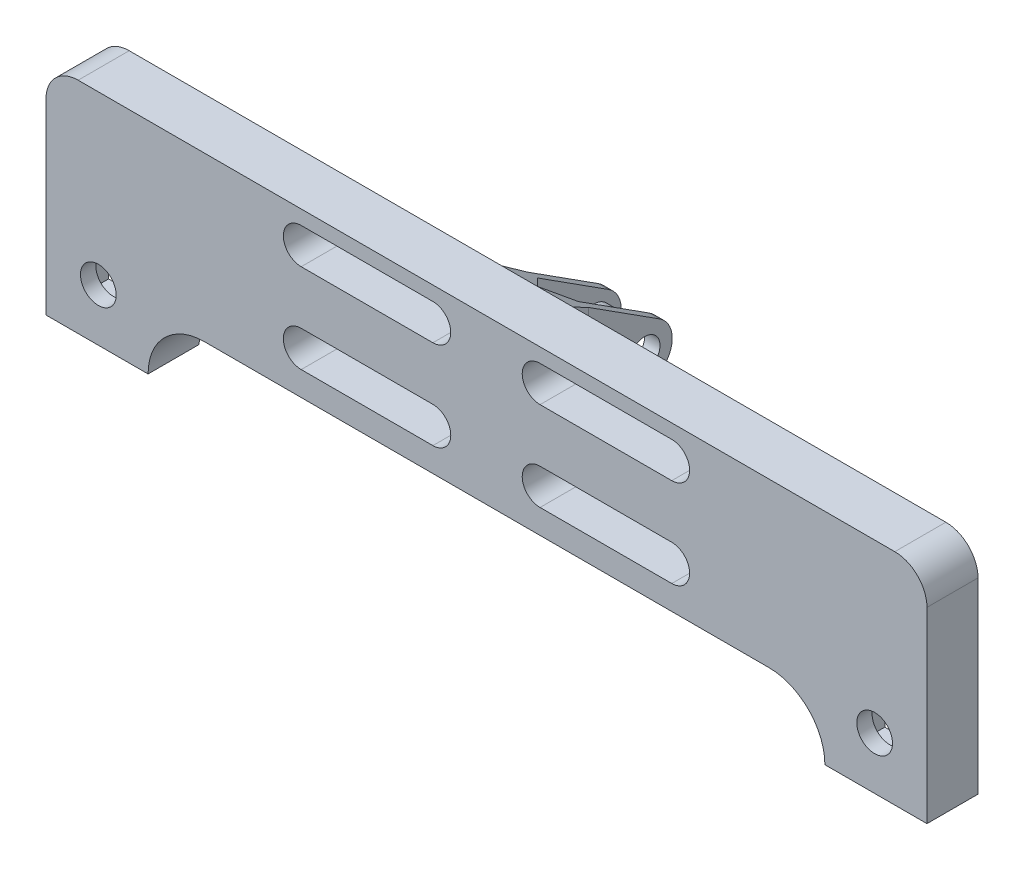
from build123d import *

# Parameters (mm, degrees)
SKETCH1_R               = 4.3000000000000025
BOSS_EXTRUDE1_DEPTH     = 8
CUT_EXTRUDE1_DEPTH      = 8
SKETCH1_2_R             = 4.3000000000000025
BOSS_EXTRUDE2_DEPTH     = 10
CUT_EXTRUDE2_DEPTH      = 92.31190849955428
CUT_EXTRUDE2_DEPTH_BACK = 92.31190849955428
SKETCH3_W               = 12.499999999999986
SKETCH3_H               = 12.500000000000002
SKETCH3_W_2             = 12.5
SKETCH3_H_2             = 12.5
BOSS_EXTRUDE3_DEPTH     = 2
BOSS_EXTRUDE5_START     = -2
SKETCH4_R               = 4.3000000000000025
BOSS_EXTRUDE5_DEPTH     = 2
BOSS_EXTRUDE6_DEPTH     = 10.000000000000002
BOSS_EXTRUDE7_DEPTH     = 10.000000000000002
BOSS_EXTRUDE8_DEPTH     = 10
SKETCH8_W               = 18.12209127979392
SKETCH8_H               = 22.505010210713824
SKETCH8_W_2             = 16.915072938743947
SKETCH8_H_2             = 18.768490123640905
BOSS_EXTRUDE9_DEPTH     = 10
SKETCH12_W              = 16.5
SKETCH12_H              = 16.500000000000004
CUT_EXTRUDE6_DEPTH      = 6.999999999999999
SKETCH13_R              = 3.5000000000000075
CUT_EXTRUDE7_DEPTH      = 6.999999999999999
CUT_EXTRUDE11_DEPTH     = 5
BOSS_EXTRUDE10_DEPTH    = 8
BOSS_EXTRUDE11_START    = -10.000000000000002
BOSS_EXTRUDE11_DEPTH    = 10.000000000000002
BOSS_EXTRUDE12_START    = -10.000000000000002
BOSS_EXTRUDE12_DEPTH    = 10.000000000000002
BOSS_EXTRUDE13_DEPTH    = 20
CUT_EXTRUDE12_DEPTH     = 20
SKETCH20_R              = 3.5
CUT_EXTRUDE13_DEPTH     = 20
SKETCH21_W              = 12.588800468492423
SKETCH21_H              = 27.872981801920105
CUT_EXTRUDE15_DEPTH     = 28.00000000000001
SKETCH23_W              = 2.0000000000000004
SKETCH23_H              = 31.999999999999986
BOSS_EXTRUDE14_DEPTH    = 25
SKETCH24_R              = 2.9999999999999996
CUT_EXTRUDE16_DEPTH     = 25
CUT_EXTRUDE18_DEPTH     = 25
BOSS_EXTRUDE15_REACH    = 105.846
CUT_EXTRUDE19_REACH     = 101.389
CUT_EXTRUDE20_REACH     = 101.389
SKETCH31_W              = 16.5
SKETCH31_H              = 16.500000000000004
BOSS_EXTRUDE16_DEPTH    = 7
SKETCH32_R              = 4.3000000000000025
SKETCH32_R_2            = 4.0500000000000025
BOSS_EXTRUDE17_DEPTH    = 10
BOSS_EXTRUDE18_START    = 2
SKETCH33_R              = 3.5000000000000018
SKETCH33_R_2            = 2.9999999999999996
BOSS_EXTRUDE18_DEPTH    = 2
SKETCH34_R              = 3.4999999999999996
SKETCH34_R_2            = 3.0000000000000013
BOSS_EXTRUDE19_DEPTH    = 1


with BuildPart() as part:
    # Sketch1 → Boss-Extrude1 (new body)
    with BuildSketch(Plane.XY):
        with BuildLine():
            Line((-85.34534606205251, -25.7), (87.25465393794748, -25.7))
            Line((87.25465393794748, -25.7), (87.25465393794748, 0))
            ThreePointArc((87.25465393794748, 0), (85.40942665942275, 4.454772721475249), (80.9546539379475, 6.3))
            Line((80.9546539379475, 6.3), (-79.04534606205252, 6.3))
            ThreePointArc((-79.04534606205252, 6.3), (-83.50011878352777, 4.4547727214752495), (-85.34534606205251, -7.7e-16))
            Line((-85.34534606205251, -7.7e-16), (-85.34534606205251, -25.7))
        make_face()
        with Locations((-79.04534606205252, 0)):
            Circle(SKETCH1_R, mode=Mode.SUBTRACT)
        with Locations((80.9546539379475, 0)):
            Circle(SKETCH1_R, mode=Mode.SUBTRACT)
        Polygon((-83.3453460620525, -11.200000000000001), (-70.8453460620525, -11.199999999999998), (-70.84534606205251, -23.7), (-83.34534606205251, -23.7), align=None, mode=Mode.SUBTRACT)
        Polygon((85.2546539379475, -11.199999999999966), (72.7546539379475, -11.199999999999967), (72.7546539379475, -23.69999999999997), (85.2546539379475, -23.699999999999967), align=None, mode=Mode.SUBTRACT)
    extrude(amount=BOSS_EXTRUDE1_DEPTH)

    # Sketch2 → Cut-Extrude1 (cut)
    with BuildSketch(Plane.XY.offset(8)):
        with BuildLine():
            Line((-35.34534606205251, 3.4999999999999996), (37.25465393794748, 3.4999999999999996))
            ThreePointArc((37.25465393794748, 3.4999999999999996), (40.75465393794748, 0), (37.25465393794748, -3.4999999999999996))
            Line((37.25465393794748, -3.4999999999999996), (-35.34534606205251, -3.4999999999999996))
            ThreePointArc((-35.34534606205251, -3.4999999999999996), (-38.84534606205251, 4.3e-16), (-35.34534606205251, 3.4999999999999996))
        make_face()
        with BuildLine():
            Line((-35.34534606205251, -13.949999999999969), (37.25465393794749, -13.949999999999969))
            ThreePointArc((37.25465393794749, -13.949999999999969), (40.75465393794748, -17.449999999999967), (37.25465393794749, -20.949999999999967))
            Line((37.25465393794749, -20.949999999999967), (34.64320743131566, -20.949999999999967))
            Line((34.64320743131566, -20.949999999999967), (-35.34534606205251, -20.949999999999967))
            ThreePointArc((-35.34534606205251, -20.949999999999967), (-38.845346062052506, -17.449999999999967), (-35.34534606205251, -13.949999999999969))
        make_face()
    extrude(amount=-CUT_EXTRUDE1_DEPTH, mode=Mode.SUBTRACT)

    # Sketch1_2 → Boss-Extrude2 (add)
    with BuildSketch(Plane.XY):
        with BuildLine():
            Line((-85.34534606205251, -25.7), (87.25465393794748, -25.7))
            Line((87.25465393794748, -25.7), (87.25465393794748, 0))
            ThreePointArc((87.25465393794748, 0), (85.40942665942275, 4.454772721475249), (80.9546539379475, 6.3))
            Line((80.9546539379475, 6.3), (-79.04534606205252, 6.3))
            ThreePointArc((-79.04534606205252, 6.3), (-83.50011878352777, 4.4547727214752495), (-85.34534606205251, -7.7e-16))
            Line((-85.34534606205251, -7.7e-16), (-85.34534606205251, -25.7))
        make_face()
        with Locations((-79.04534606205252, 0)):
            Circle(SKETCH1_2_R, mode=Mode.SUBTRACT)
        with Locations((80.9546539379475, 0)):
            Circle(SKETCH1_2_R, mode=Mode.SUBTRACT)
        Polygon((-83.3453460620525, -11.200000000000001), (-70.8453460620525, -11.199999999999998), (-70.84534606205251, -23.7), (-83.34534606205251, -23.7), align=None, mode=Mode.SUBTRACT)
        Polygon((85.2546539379475, -11.199999999999966), (72.7546539379475, -11.199999999999967), (72.7546539379475, -23.69999999999997), (85.2546539379475, -23.699999999999967), align=None, mode=Mode.SUBTRACT)
    extrude(amount=BOSS_EXTRUDE2_DEPTH)

    # Sketch2_2 → Cut-Extrude2 (cut, two sides: drawn at the far end of the back side and taken through both)
    with BuildSketch(Plane.XY.offset(8).offset(-CUT_EXTRUDE2_DEPTH_BACK)):
        with BuildLine():
            Line((-35.34534606205251, 3.4999999999999996), (37.25465393794748, 3.4999999999999996))
            ThreePointArc((37.25465393794748, 3.4999999999999996), (40.75465393794748, 0), (37.25465393794748, -3.4999999999999996))
            Line((37.25465393794748, -3.4999999999999996), (-35.34534606205251, -3.4999999999999996))
            ThreePointArc((-35.34534606205251, -3.4999999999999996), (-38.84534606205251, 4.3e-16), (-35.34534606205251, 3.4999999999999996))
        make_face()
        with BuildLine():
            Line((-35.34534606205251, -13.949999999999969), (37.25465393794749, -13.949999999999969))
            ThreePointArc((37.25465393794749, -13.949999999999969), (40.75465393794748, -17.449999999999967), (37.25465393794749, -20.949999999999967))
            Line((37.25465393794749, -20.949999999999967), (34.64320743131566, -20.949999999999967))
            Line((34.64320743131566, -20.949999999999967), (-35.34534606205251, -20.949999999999967))
            ThreePointArc((-35.34534606205251, -20.949999999999967), (-38.845346062052506, -17.449999999999967), (-35.34534606205251, -13.949999999999969))
        make_face()
    extrude(amount=CUT_EXTRUDE2_DEPTH + CUT_EXTRUDE2_DEPTH_BACK, mode=Mode.SUBTRACT)

    # Sketch3 → Boss-Extrude3 (add)
    with BuildSketch(Plane.XY.offset(10)):
        with Locations((-77.0953460620525, -17.450000000000003)):
            Rectangle(SKETCH3_W, SKETCH3_H)
        with Locations((79.0046539379475, -17.449999999999967)):
            Rectangle(SKETCH3_W_2, SKETCH3_H_2)
    extrude(amount=-BOSS_EXTRUDE3_DEPTH)

    # Sketch4 → Boss-Extrude5 (add)
    with BuildSketch(Plane.XY.offset(10).offset(BOSS_EXTRUDE5_START)):
        with Locations((-79.04534606205252, 0)):
            Circle(SKETCH4_R)
        with Locations((80.9546539379475, 0)):
            Circle(SKETCH4_R)
    extrude(amount=BOSS_EXTRUDE5_DEPTH)

    # Sketch5 → Boss-Extrude6 (add)
    with BuildSketch(Plane.XY.offset(10)):
        with BuildLine():
            Line((-4.5453460620525155, 3.4999999999999996), (6.454653937947482, 3.4999999999999996))
            ThreePointArc((6.454653937947482, 3.4999999999999996), (2.954653937947483, 4.3e-16), (6.454653937947483, -3.4999999999999996))
            Line((6.454653937947483, -3.4999999999999996), (-4.545346062052516, -3.4999999999999996))
            ThreePointArc((-4.545346062052516, -3.4999999999999996), (-1.0453460620525168, -7.8e-16), (-4.5453460620525155, 3.4999999999999996))
        make_face()
    extrude(amount=-BOSS_EXTRUDE6_DEPTH)

    # Sketch6 → Boss-Extrude7 (add)
    with BuildSketch(Plane.XY.offset(10)):
        with BuildLine():
            Line((-4.545346062052515, -13.949999999999969), (6.454653937947488, -13.949999999999969))
            ThreePointArc((6.454653937947488, -13.949999999999969), (2.9546539379474925, -17.449999999999964), (6.454653937947487, -20.949999999999967))
            Line((6.454653937947487, -20.949999999999967), (-4.545346062052514, -20.949999999999967))
            ThreePointArc((-4.545346062052514, -20.949999999999967), (-1.045346062052519, -17.449999999999964), (-4.545346062052515, -13.949999999999969))
        make_face()
    extrude(amount=-BOSS_EXTRUDE7_DEPTH)

    # Sketch7 → Boss-Extrude8 (add)
    with BuildSketch(Plane.XY.offset(10)):
        with BuildLine():
            Line((-85.34534606205251, -25.7), (-85.34534606205251, -36.7))
            Line((-85.34534606205251, -36.7), (-65.34534606205251, -36.7))
            ThreePointArc((-65.34534606205251, -36.7), (-62.123520655104535, -28.92182540694798), (-54.34534606205251, -25.7))
            Line((-54.34534606205251, -25.7), (-85.34534606205251, -25.7))
        make_face()
        with BuildLine():
            Line((87.25465393794748, -25.7), (87.25465393794748, -36.7))
            Line((87.25465393794748, -36.7), (67.25465393794748, -36.7))
            ThreePointArc((67.25465393794748, -36.7), (64.03282853099951, -28.92182540694797), (56.25465393794748, -25.7))
            Line((56.25465393794748, -25.7), (87.25465393794748, -25.7))
        make_face()
    extrude(amount=-BOSS_EXTRUDE8_DEPTH)

    # Sketch8 → Boss-Extrude9 (add)
    with BuildSketch(Plane(origin=(0, 0, 0), x_dir=(-1, 0, 0), z_dir=(0, 0, -1))):
        with Locations((-77.42693865318739, -19.427407937710136)):
            Rectangle(SKETCH8_W, SKETCH8_H)
        with Locations((75.82994568606472, -18.53584079527426)):
            Rectangle(SKETCH8_W_2, SKETCH8_H_2)
    extrude(amount=-BOSS_EXTRUDE9_DEPTH)

    # Sketch12 → Cut-Extrude6 (cut)
    with BuildSketch(Plane(origin=(0, 0, 0), x_dir=(-1, 0, 0), z_dir=(0, 0, -1))):
        with Locations((-77.00465393794748, -26.450000000000003)):
            Rectangle(SKETCH12_W, SKETCH12_H)
        with Locations((75.09534606205251, -26.450000000000003)):
            Rectangle(SKETCH12_W, SKETCH12_H)
    extrude(amount=-CUT_EXTRUDE6_DEPTH, mode=Mode.SUBTRACT)

    # Sketch13 → Cut-Extrude7 (cut)
    with BuildSketch(Plane(origin=(0, 0, 6.999999999999999), x_dir=(-1, 0, 0), z_dir=(0, 0, -1))):
        with Locations((75.09534606205253, -26.450000000000003)):
            Circle(SKETCH13_R)
        with Locations((-77.0046539379475, -26.450000000000003)):
            Circle(SKETCH13_R)
    extrude(amount=-CUT_EXTRUDE7_DEPTH, mode=Mode.SUBTRACT)

    # Sketch14 → Cut-Extrude11 (cut)
    with BuildSketch(Plane(origin=(0, 0, 0), x_dir=(-1, 0, 0), z_dir=(0, 0, -1))):
        with BuildLine():
            Line((-75.9546539379475, -5.499999999999989), (-5.954653937947485, -5.499999999999989))
            ThreePointArc((-5.954653937947485, -5.499999999999989), (-2.729653937947491, -8.724999999999984), (-5.954653937947485, -11.949999999999978))
            Line((-5.954653937947485, -11.949999999999978), (-75.9546539379475, -11.949999999999989))
            ThreePointArc((-75.9546539379475, -11.949999999999989), (-79.1796539379475, -8.724999999999984), (-75.9546539379475, -5.499999999999989))
        make_face()
        with BuildLine():
            Line((4.0453460620525155, -5.499999999999981), (6.774875552501669, -5.499999999999981))
            Line((6.774875552501669, -5.499999999999981), (74.04534606205253, -5.499999999999982))
            ThreePointArc((74.04534606205253, -5.499999999999982), (77.27034606205254, -8.724999999999985), (74.04534606205253, -11.949999999999969))
            Line((74.04534606205253, -11.949999999999969), (4.045346062052515, -11.949999999999978))
            ThreePointArc((4.045346062052515, -11.949999999999978), (0.820346062052522, -8.724999999999985), (4.0453460620525155, -5.499999999999981))
        make_face()
    extrude(amount=-CUT_EXTRUDE11_DEPTH, mode=Mode.SUBTRACT)

    # Sketch15 → Boss-Extrude10 (add)
    with BuildSketch(Plane(origin=(0, 0, 0), x_dir=(-1, 0, 0), z_dir=(0, 0, -1))):
        with BuildLine():
            Line((-75.95465393794751, -5.499999999999987), (-5.954653937947488, -5.499999999999989))
            ThreePointArc((-5.954653937947488, -5.499999999999989), (-2.729653937947492, -8.724999999999982), (-5.954653937947485, -11.949999999999978))
            Line((-5.954653937947485, -11.949999999999978), (-75.95465393794747, -11.949999999999982))
            ThreePointArc((-75.95465393794747, -11.949999999999982), (-79.17965393794748, -8.725000000000005), (-75.95465393794751, -5.499999999999987))
        make_face()
        with BuildLine():
            Line((4.045346062052503, -5.499999999999988), (74.04534606205252, -5.499999999999988))
            ThreePointArc((74.04534606205252, -5.499999999999988), (77.27034606205251, -8.724999999999977), (74.04534606205253, -11.94999999999998))
            Line((74.04534606205253, -11.94999999999998), (4.045346062052521, -11.949999999999978))
            ThreePointArc((4.045346062052521, -11.949999999999978), (0.8203460620525185, -8.724999999999993), (4.045346062052503, -5.499999999999988))
        make_face()
    extrude(amount=-BOSS_EXTRUDE10_DEPTH)

    # Sketch16 → Boss-Extrude11 (add)
    with BuildSketch(Plane(origin=(0, 0, 0), x_dir=(-1, 0, 0), z_dir=(0, 0, -1)).offset(BOSS_EXTRUDE11_START)):
        with BuildLine():
            Line((4.545346062052515, -3.4999999999999996), (9.545346062052516, -3.499999999999999))
            ThreePointArc((9.545346062052516, -3.499999999999999), (6.045346062052516, 1e-17), (9.545346062052516, 3.4999999999999996))
            Line((9.545346062052516, 3.4999999999999996), (4.545346062052515, 3.4999999999999996))
            ThreePointArc((4.545346062052515, 3.4999999999999996), (1.045346062052515, 4.3e-16), (4.545346062052515, -3.4999999999999996))
        make_face()
    boss_extrude11 = extrude(amount=BOSS_EXTRUDE11_DEPTH)

    # Mirror1: Boss-Extrude11 across plane
    add(boss_extrude11.mirror(Plane.ZY.offset(-0.9546539379474833)))

    # Sketch17 → Boss-Extrude12 (add)
    with BuildSketch(Plane(origin=(0, 0, 0), x_dir=(-1, 0, 0), z_dir=(0, 0, -1)).offset(BOSS_EXTRUDE12_START)):
        with BuildLine():
            Line((9.545346062052516, -20.949999999999967), (4.545346062052515, -20.949999999999967))
            ThreePointArc((4.545346062052515, -20.949999999999967), (1.0453460620525146, -17.449999999999967), (4.545346062052515, -13.949999999999969))
            Line((4.545346062052515, -13.949999999999969), (9.545346062052516, -13.949999999999969))
            ThreePointArc((9.545346062052516, -13.949999999999969), (6.045346062052518, -17.449999999999967), (9.545346062052516, -20.949999999999967))
        make_face()
    boss_extrude12 = extrude(amount=BOSS_EXTRUDE12_DEPTH)

    # Mirror2: Boss-Extrude12 across plane
    add(boss_extrude12.mirror(Plane.ZY.offset(-0.9546539379474833)))

    # Sketch18 → Boss-Extrude13 (add)
    with BuildSketch(Plane(origin=(0, 0, 0), x_dir=(-1, 0, 0), z_dir=(0, 0, -1))):
        Polygon((-5.954653937947488, 2.3000000000000207), (-3.9546539379474877, 2.3000000000000207), (-3.954653937947485, -17.699999999999978), (-5.9546539379474845, -17.699999999999978), align=None)
        Polygon((2.0453460620525137, 2.3000000000000207), (4.045346062052515, 2.3000000000000207), (4.045346062052516, -17.699999999999978), (2.0453460620525163, -17.699999999999978), align=None)
    extrude(amount=BOSS_EXTRUDE13_DEPTH)

    # Sketch19 → Cut-Extrude12 (cut)
    with BuildSketch(Plane.ZY.offset(4.045346062052515)):
        Polygon((0, 2.3000000000000203), (-20, -4.699999999999979), (-20, 2.3000000000000203), align=None)
        Polygon((0, -17.699999999999978), (-20, -17.699999999999978), (-20, -10.69999999999998), align=None)
    extrude(amount=-CUT_EXTRUDE12_DEPTH, mode=Mode.SUBTRACT)

    # Sketch20 → Cut-Extrude13 (cut)
    with BuildSketch(Plane.ZY.offset(4.045346062052515)):
        with Locations(Location((-15, -7.69999999999998, 0), (0, 0, 270))):
            Circle(SKETCH20_R)
    extrude(amount=-CUT_EXTRUDE13_DEPTH, mode=Mode.SUBTRACT)

    # Sketch21 → Cut-Extrude15 (cut)
    with BuildSketch(Plane(origin=(0, 0, 0), x_dir=(-1, 0, 0), z_dir=(0, 0, -1))):
        with Locations((-0.5300969409489649, -9.126679055583509)):
            Rectangle(SKETCH21_W, SKETCH21_H)
    extrude(amount=CUT_EXTRUDE15_DEPTH, mode=Mode.SUBTRACT)

    # Sketch23 → Boss-Extrude14 (add)
    with BuildSketch(Plane(origin=(0, 0, 0), x_dir=(-1, 0, 0), z_dir=(0, 0, -1))):
        with Locations((4.045346062052517, -9.699999999999989)):
            Rectangle(SKETCH23_W, SKETCH23_H)
        Polygon((-4.954653937947484, -25.69999999999998), (-6.954653937947484, -25.699999999999985), (-6.954653937947484, 6.300000000000005), (-4.954653937947484, 6.300000000000004), align=None)
    extrude(amount=BOSS_EXTRUDE14_DEPTH)

    # Sketch24 → Cut-Extrude16 (cut)
    with BuildSketch(Plane(origin=(6.954653937947484, 0, 0), x_dir=(0, 0, -1), z_dir=(1, 0, 0))):
        with Locations((15.000000000000002, -9.69999999999999)):
            Circle(SKETCH24_R)
    extrude(amount=-CUT_EXTRUDE16_DEPTH, mode=Mode.SUBTRACT)

    # Sketch25 → Cut-Extrude18 (cut)
    with BuildSketch(Plane(origin=(6.954653937947484, 0, 0), x_dir=(0, 0, -1), z_dir=(1, 0, 0))):
        with BuildLine():
            Line((17.905788876276958, -14.24029511918274), (0, -25.699999999999985))
            Line((0, -25.699999999999985), (25, -25.699999999999985))
            Line((25, -25.699999999999985), (25, -9.699999999999992))
            Line((25, -9.699999999999992), (25, 6.300000000000005))
            Line((25, 6.300000000000005), (0, 6.300000000000005))
            Line((0, 6.300000000000005), (17.905788876276958, -5.1597048808172445))
            ThreePointArc((17.905788876276958, -5.1597048808172445), (20.39053696423367, -9.699999999999992), (17.905788876276958, -14.24029511918274))
        make_face()
    extrude(amount=-CUT_EXTRUDE18_DEPTH, mode=Mode.SUBTRACT)

    # Boss-Extrude15: up to this plane
    boss_extrude15_end = Plane(origin=(-18.04534606205252, -14.24029511918274, -17.905788876276958), z_dir=(0, 0.8422714006615116, 0.5390536964233671))
    # Sketch28 → Boss-Extrude15 (add, up to the surface)
    with BuildSketch(Plane(origin=(6.954653937947484, 6.300000000000005, 0), x_dir=(-1, 0, 0), z_dir=(0, -1, 0)), mode=Mode.PRIVATE) as boss_extrude15_sk1:
        Polygon((6, 0), (2, 0), (2, 4), align=None)
    boss_extrude15_tool1 = split(extrude(boss_extrude15_sk1.sketch, amount=BOSS_EXTRUDE15_REACH, mode=Mode.PRIVATE), bisect_by=boss_extrude15_end, keep=Keep.BOTH, mode=Mode.PRIVATE)
    add(boss_extrude15_tool1.solids().sort_by_distance((3.621321, 6.3, -1.333333))[0])
    # Sketch28 → Boss-Extrude15 (add, up to the surface)
    with BuildSketch(Plane(origin=(6.954653937947484, 6.300000000000005, 0), x_dir=(-1, 0, 0), z_dir=(0, -1, 0)), mode=Mode.PRIVATE) as boss_extrude15_sk2:
        Polygon((10, 4), (6, 0), (10, 0), align=None)
    boss_extrude15_tool2 = split(extrude(boss_extrude15_sk2.sketch, amount=BOSS_EXTRUDE15_REACH, mode=Mode.PRIVATE), bisect_by=boss_extrude15_end, keep=Keep.BOTH, mode=Mode.PRIVATE)
    add(boss_extrude15_tool2.solids().sort_by_distance((-1.712013, 6.3, -1.333333))[0])
    # Sketch28 → Boss-Extrude15 (add, up to the surface)
    with BuildSketch(Plane(origin=(6.954653937947484, 6.300000000000005, 0), x_dir=(-1, 0, 0), z_dir=(0, -1, 0)), mode=Mode.PRIVATE) as boss_extrude15_sk3:
        Polygon((13.000000000000002, 0), (12, 4), (12, 0), align=None)
    boss_extrude15_tool3 = split(extrude(boss_extrude15_sk3.sketch, amount=BOSS_EXTRUDE15_REACH, mode=Mode.PRIVATE), bisect_by=boss_extrude15_end, keep=Keep.BOTH, mode=Mode.PRIVATE)
    add(boss_extrude15_tool3.solids().sort_by_distance((-5.378679, 6.3, -1.333333))[0])
    # Sketch28 → Boss-Extrude15 (add, up to the surface)
    with BuildSketch(Plane(origin=(6.954653937947484, 6.300000000000005, 0), x_dir=(-1, 0, 0), z_dir=(0, -1, 0)), mode=Mode.PRIVATE) as boss_extrude15_sk4:
        Polygon((0, 4), (-1, 0), (0, 0), align=None)
    boss_extrude15_tool4 = split(extrude(boss_extrude15_sk4.sketch, amount=BOSS_EXTRUDE15_REACH, mode=Mode.PRIVATE), bisect_by=boss_extrude15_end, keep=Keep.BOTH, mode=Mode.PRIVATE)
    add(boss_extrude15_tool4.solids().sort_by_distance((7.287987, 6.3, -1.333333))[0])

    # Cut-Extrude19: up to this face of the body (flat: up to its plane)
    cut_extrude19_end = Plane(part.part.faces().sort_by_distance((-4.045346062, 0.57014756, -8.952894438))[0])
    # Sketch29 → Cut-Extrude19 (cut, up to the picked face)
    with BuildSketch(Plane(origin=(0, 6.3, 0), x_dir=(1, 0, 0), z_dir=(0, 1, 0)), mode=Mode.PRIVATE) as cut_extrude19_sk1:
        Polygon((-5.045346062052517, 0), (-6.045346062052526, 1.73e-15), (-5.045346062052517, 3.999999999999999), align=None)
    cut_extrude19_tool1 = split(extrude(cut_extrude19_sk1.sketch, amount=-CUT_EXTRUDE19_REACH, mode=Mode.PRIVATE), bisect_by=cut_extrude19_end, keep=Keep.BOTH, mode=Mode.PRIVATE)
    # Sketch29 → Cut-Extrude19 (cut, up to the picked face)
    with BuildSketch(Plane(origin=(0, 6.3, 0), x_dir=(1, 0, 0), z_dir=(0, 1, 0)), mode=Mode.PRIVATE) as cut_extrude19_sk2:
        Polygon((-3.045346062052517, 0), (-3.045346062052517, 4), (0.9546539379474833, 0), align=None)
    cut_extrude19_tool2 = split(extrude(cut_extrude19_sk2.sketch, amount=-CUT_EXTRUDE19_REACH, mode=Mode.PRIVATE), bisect_by=cut_extrude19_end, keep=Keep.BOTH, mode=Mode.PRIVATE)
    add(cut_extrude19_tool1.solids().sort_by(Axis((-5.378679, 6.3, -1.333333), (0, -1, 0)))[0], mode=Mode.SUBTRACT)
    add(cut_extrude19_tool2.solids().sort_by(Axis((-1.712013, 6.3, -1.333333), (0, -1, 0)))[0], mode=Mode.SUBTRACT)

    # Cut-Extrude20: up to this face of the body (flat: up to its plane)
    cut_extrude20_end = Plane(part.part.faces().sort_by_distance((5.954653938, 0.57014756, -8.952894438))[0])
    # Sketch30 → Cut-Extrude20 (cut, up to the picked face)
    with BuildSketch(Plane(origin=(0, 6.3, 0), x_dir=(1, 0, 0), z_dir=(0, 1, 0)), mode=Mode.PRIVATE) as cut_extrude20_sk1:
        Polygon((0.9546539379474833, 0), (4.954653937947484, 0), (4.954653937947484, 4), align=None)
    cut_extrude20_tool1 = split(extrude(cut_extrude20_sk1.sketch, amount=-CUT_EXTRUDE20_REACH, mode=Mode.PRIVATE), bisect_by=cut_extrude20_end, keep=Keep.BOTH, mode=Mode.PRIVATE)
    # Sketch30 → Cut-Extrude20 (cut, up to the picked face)
    with BuildSketch(Plane(origin=(0, 6.3, 0), x_dir=(1, 0, 0), z_dir=(0, 1, 0)), mode=Mode.PRIVATE) as cut_extrude20_sk2:
        Polygon((6.954653937947484, 0), (7.954653937947483, 0), (6.954653937947484, 4), align=None)
    cut_extrude20_tool2 = split(extrude(cut_extrude20_sk2.sketch, amount=-CUT_EXTRUDE20_REACH, mode=Mode.PRIVATE), bisect_by=cut_extrude20_end, keep=Keep.BOTH, mode=Mode.PRIVATE)
    add(cut_extrude20_tool1.solids().sort_by(Axis((3.621321, 6.3, -1.333333), (0, -1, 0)))[0], mode=Mode.SUBTRACT)
    add(cut_extrude20_tool2.solids().sort_by(Axis((7.287987, 6.3, -1.333333), (0, -1, 0)))[0], mode=Mode.SUBTRACT)

    # Sketch31 → Boss-Extrude16 (add)
    with BuildSketch(Plane(origin=(0, 0, 6.999999999999999), x_dir=(-1, 0, 0), z_dir=(0, 0, -1))):
        with Locations((-77.00465393794748, -26.450000000000003)):
            Rectangle(SKETCH31_W, SKETCH31_H)
        Polygon((-85.00465393794748, -34.45), (-69.00465393794748, -34.449999999999996), (-69.00465393794748, -18.449999999999996), (-85.00465393794748, -18.449999999999996), align=None, mode=Mode.SUBTRACT)
    boss_extrude16 = extrude(amount=BOSS_EXTRUDE16_DEPTH)

    # Mirror3: Boss-Extrude16 across plane
    add(boss_extrude16.mirror(Plane(origin=(0.9546539379474833, 0, 0), x_dir=(0, 0, 1), z_dir=(1, 0, 0))))

    # Sketch32 → Boss-Extrude17 (add)
    with BuildSketch(Plane(origin=(0, 0, 0), x_dir=(-1, 0, 0), z_dir=(0, 0, -1))):
        with Locations((-80.9546539379475, 0)):
            Circle(SKETCH32_R)
        with Locations((-80.9546539379475, 0)):
            Circle(SKETCH32_R_2, mode=Mode.SUBTRACT)
    boss_extrude17 = extrude(amount=-BOSS_EXTRUDE17_DEPTH)

    # Mirror4: Boss-Extrude17 across plane
    add(boss_extrude17.mirror(Plane(origin=(0.9546539379474833, 0, 0), x_dir=(0, 0, 1), z_dir=(1, 0, 0))))

    # Sketch33 → Boss-Extrude18 (add)
    with BuildSketch(Plane(origin=(-3.045346062052517, 0, 0), x_dir=(0, 0, -1), z_dir=(1, 0, 0)).offset(BOSS_EXTRUDE18_START)):
        with Locations(Location((15.000000000000002, -9.69999999999999, 0), (0, 0, 180))):
            Circle(SKETCH33_R)
        with Locations((15.000000000000002, -9.69999999999999)):
            Circle(SKETCH33_R_2, mode=Mode.SUBTRACT)
    extrude(amount=-BOSS_EXTRUDE18_DEPTH)

    # Sketch34 → Boss-Extrude19 (add)
    with BuildSketch(Plane.ZY.offset(-4.954653937947484)):
        with Locations((-15.000000000000002, -9.69999999999999)):
            Circle(SKETCH34_R)
        with Locations(Location((-15.000000000000002, -9.69999999999999, 0), (0, 0, 180))):
            Circle(SKETCH34_R_2, mode=Mode.SUBTRACT)
    extrude(amount=BOSS_EXTRUDE19_DEPTH)


solid = part.part
